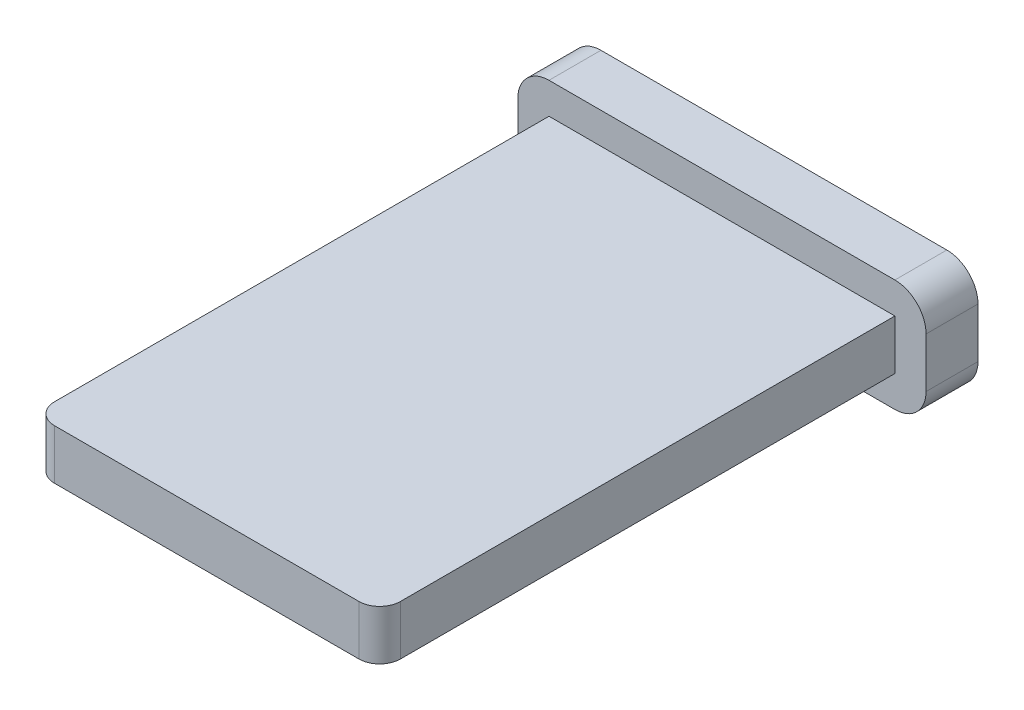
from build123d import *

# Parameters (mm, degrees)
SKETCH1_W           = 33.3
SKETCH1_H           = 4.8
BOSS_EXTRUDE1_DEPTH = 49.6
FILLET1_R           = 2
SKETCH2_W           = 39.3
SKETCH2_H           = 10.8
BOSS_EXTRUDE2_DEPTH = 5
FILLET2_R           = 3
SKETCH3_W           = 0.284935898
SKETCH3_H           = 3.175
SKETCH3_W_2         = 0.284935897
SKETCH3_H_2         = 3.256410257
CUT_EXTRUDE1_DEPTH  = 2


with BuildPart() as part:
    # Sketch1 → Boss-Extrude1 (new body)
    with BuildSketch(Plane.XY):
        with Locations((0.05, 3.701923077)):
            Rectangle(SKETCH1_W, SKETCH1_H)
    extrude(amount=BOSS_EXTRUDE1_DEPTH)

    # Fillet1
    fillet1_edges = [part.edges().sort_by_distance(p)[0] for p in [
        (16.7, 3.701923077, 49.6),
        (-16.6, 3.701923077, 49.6),
    ]]
    fillet(fillet1_edges, radius=FILLET1_R)

    # Sketch2 → Boss-Extrude2 (add)
    with BuildSketch(Plane(origin=(0, 0, 0), x_dir=(-1, 0, 0), z_dir=(0, 0, -1))):
        with Locations((-0.05, 3.701923077)):
            Rectangle(SKETCH2_W, SKETCH2_H)
    extrude(amount=BOSS_EXTRUDE2_DEPTH)

    # Fillet2
    fillet2_edges = [part.edges().sort_by_distance(p)[0] for p in [
        (19.7, 9.101923077, -2.5),
        (19.7, -1.698076923, -2.5),
        (-19.6, -1.698076923, -2.5),
        (-19.6, 9.101923077, -2.5),
    ]]
    fillet(fillet2_edges, radius=FILLET2_R)

    # Sketch3 → Cut-Extrude1 (cut)
    with BuildSketch(Plane(origin=(0, 0, -5), x_dir=(-1, 0, 0), z_dir=(0, 0, -1))):
        with Locations((-13.121509951, 5.188376866)):
            Rectangle(SKETCH3_W, SKETCH3_H)
        Polygon((-11.961413797, 6.857287123), (-11.6764779, 6.857287123), (-11.6764779, 5.921069174), (-11.269426618, 5.921069174), (-11.269426618, 5.636133277), (-11.6764779, 5.636133277), (-11.6764779, 3.600876866), (-11.961413797, 3.600876866), (-11.961413797, 5.636133277), (-12.368465079, 5.636133277), (-12.368465079, 5.921069174), (-11.961413797, 5.921069174), align=None)
        with BuildLine():
            Line((-8.420067644, 5.921069174), (-8.420067644, 3.600876866))
            Line((-8.420067644, 3.600876866), (-8.705003541, 3.600876866))
            Line((-8.705003541, 3.600876866), (-8.705003541, 4.00220399))
            add(Edge.make_bspline(
                [(-8.705003541, 4.00220399), (-8.737133444, 3.965882358), (-8.799835353, 3.895000237), (-8.904556939, 3.802397124), (-9.015562358, 3.725853932), (-9.132312842, 3.664032223), (-9.254702962, 3.617593714), (-9.382461413, 3.58458627), (-9.515640309, 3.56336472), (-9.606583516, 3.561245614), (-9.652669807, 3.560171738)],
                knots=[0, 0, 0, 0, 1.074387032, 2.096679803, 3.090159297, 4.057316773, 5.018401886, 5.985159533, 6.978961417, 8, 8, 8, 8], degree=3))
            add(Edge.make_bspline(
                [(-9.652669807, 3.560171738), (-9.693643594, 3.561284233), (-9.774445715, 3.563478122), (-9.893307807, 3.580498212), (-10.00769149, 3.60783099), (-10.117704852, 3.645841083), (-10.222636013, 3.696260828), (-10.323383386, 3.756623246), (-10.419425043, 3.828505999), (-10.509297082, 3.910682282), (-10.592057539, 3.999940592), (-10.664684551, 4.095141195), (-10.72523913, 4.195872428), (-10.775875918, 4.300858931), (-10.814879744, 4.410908894), (-10.842070113, 4.525641754), (-10.859070375, 4.644921853), (-10.861263357, 4.726146992), (-10.862375336, 4.767333197)],
                knots=[0, 0, 0, 0, 1.033919861, 2.038935746, 3.024066025, 3.998881131, 4.97069526, 5.957263378, 6.95902576, 7.993208707, 9.027059324, 10.027763471, 11.009749337, 11.988697705, 12.965288445, 13.950418724, 14.960734635, 16, 16, 16, 16], degree=3))
            add(Edge.make_bspline(
                [(-10.862375336, 4.767333197), (-10.861238712, 4.807668128), (-10.858991667, 4.88740811), (-10.842251961, 5.004682358), (-10.814102403, 5.117638209), (-10.774598284, 5.225912007), (-10.723941653, 5.329634767), (-10.662321174, 5.428879847), (-10.589732397, 5.523920657), (-10.506046285, 5.612522413), (-10.415391172, 5.694365399), (-10.31840968, 5.765493604), (-10.217514275, 5.82692246), (-10.111139973, 5.875593828), (-10.000861242, 5.914972087), (-9.885696331, 5.94221628), (-9.766124398, 5.958270278), (-9.684943738, 5.960595071), (-9.64376556, 5.961774302)],
                knots=[0, 0, 0, 0, 1.020392517, 2.01726096, 2.990465484, 3.961182959, 4.928053699, 5.906110375, 6.912531644, 7.948652711, 8.985773172, 9.998621852, 10.987621588, 11.969261332, 12.953316658, 13.946091881, 14.958173133, 16, 16, 16, 16], degree=3))
            add(Edge.make_bspline(
                [(-9.64376556, 5.961774302), (-9.596412831, 5.960470056), (-9.503556364, 5.957912491), (-9.367731669, 5.936628446), (-9.239239893, 5.900670693), (-9.117089159, 5.85175982), (-9.001718109, 5.786764187), (-8.894218973, 5.704776651), (-8.793466713, 5.606314289), (-8.735064591, 5.530685386), (-8.705003541, 5.491757275)],
                knots=[0, 0, 0, 0, 1.038897134, 2.037228247, 3.008116434, 3.962042015, 4.918381754, 5.904844433, 6.921570401, 8, 8, 8, 8], degree=3))
            Line((-8.705003541, 5.491757275), (-8.705003541, 5.921069174))
            Line((-8.705003541, 5.921069174), (-8.420067644, 5.921069174))
        make_face()
        with BuildLine():
            add(Edge.make_bspline(
                [(-9.639949454, 5.676838405), (-9.681600318, 5.675356462), (-9.763812498, 5.672431343), (-9.884502414, 5.649595386), (-9.999993868, 5.611600076), (-10.109709236, 5.559637208), (-10.211915404, 5.494296854), (-10.303258948, 5.415265314), (-10.38448697, 5.324698879), (-10.452802324, 5.223006251), (-10.508492275, 5.113987554), (-10.547650939, 5.000028242), (-10.573476614, 4.883183727), (-10.576115057, 4.80393329), (-10.577439438, 4.764153108)],
                knots=[0, 0, 0, 0, 1.031046209, 2.035121221, 3.029706178, 4.034933723, 5.034054252, 6.02443088, 7.017295772, 8.038157696, 9.050218397, 10.03989886, 11.016116709, 12, 12, 12, 12], degree=3))
            add(Edge.make_bspline(
                [(-10.577439438, 4.764153108), (-10.575747714, 4.724610654), (-10.572370895, 4.645680738), (-10.548104194, 4.528676929), (-10.507391737, 4.414690763), (-10.451836438, 4.304689719), (-10.382270714, 4.202559856), (-10.301636008, 4.110267031), (-10.209152538, 4.030901476), (-10.106711157, 3.964464534), (-9.997302498, 3.910795676), (-9.882246003, 3.87345256), (-9.763704531, 3.849342716), (-9.683102771, 3.846526512), (-9.642493525, 3.845107636)],
                knots=[0, 0, 0, 0, 0.979072187, 1.954306742, 2.945804271, 3.96968567, 4.997920485, 5.998718438, 6.996577872, 8.005894225, 9.015743152, 10.005417472, 10.995077863, 12, 12, 12, 12], degree=3))
            add(Edge.make_bspline(
                [(-9.642493525, 3.845107636), (-9.601267055, 3.84661346), (-9.519271694, 3.849608395), (-9.398223723, 3.872542115), (-9.280753293, 3.910432382), (-9.168460593, 3.962955161), (-9.063852388, 4.028049334), (-8.969965028, 4.104255766), (-8.890575542, 4.192886512), (-8.823272246, 4.290292294), (-8.770498832, 4.397073891), (-8.732057693, 4.510769907), (-8.709330221, 4.6313843), (-8.706465709, 4.713810862), (-8.705003541, 4.755884879)],
                knots=[0, 0, 0, 0, 1.01762866, 2.023962475, 3.030623092, 4.058876274, 5.077231937, 6.066672613, 7.034107872, 8.005628644, 8.981990164, 9.965428785, 10.961468474, 12, 12, 12, 12], degree=3))
            add(Edge.make_bspline(
                [(-8.705003541, 4.755884879), (-8.705874086, 4.78794134), (-8.707587595, 4.851038599), (-8.720678183, 4.943682847), (-8.741501581, 5.032341298), (-8.770844178, 5.117107166), (-8.809389843, 5.197511787), (-8.855878888, 5.274132484), (-8.911128832, 5.346570754), (-8.974250277, 5.413829111), (-9.043342997, 5.475175974), (-9.116453759, 5.529934963), (-9.194448765, 5.574919064), (-9.276016363, 5.612149361), (-9.361298073, 5.641775875), (-9.45098785, 5.661540426), (-9.544132359, 5.675111574), (-9.607674138, 5.676256734), (-9.639949454, 5.676838405)],
                knots=[0, 0, 0, 0, 1.050140795, 2.067009409, 3.05949893, 4.030605086, 5.00011959, 5.97591094, 6.962425594, 7.979863591, 8.993523472, 9.986985069, 10.967611495, 11.937549037, 12.921786183, 13.919465291, 14.943216303, 16, 16, 16, 16], degree=3))
        make_face(mode=Mode.SUBTRACT)
        with Locations((-7.667022772, 5.229081995)):
            Rectangle(SKETCH3_W_2, SKETCH3_H_2)
        with BuildLine():
            add(Edge.make_bspline(
                [(-5.752609711, 5.961774302), (-5.70907477, 5.960847301), (-5.623713392, 5.959029678), (-5.498701952, 5.939603245), (-5.379371722, 5.909896707), (-5.265265676, 5.868828933), (-5.15784518, 5.813781735), (-5.055545551, 5.748096164), (-4.958647264, 5.670279097), (-4.900569231, 5.610082849), (-4.871089278, 5.579527708)],
                knots=[0, 0, 0, 0, 1.054011418, 2.066658804, 3.057071809, 4.030435133, 4.997543892, 5.974964718, 6.972108034, 8, 8, 8, 8], degree=3))
            add(Edge.make_bspline(
                [(-4.871089278, 5.579527708), (-4.845705648, 5.550305021), (-4.795429632, 5.492425186), (-4.730962873, 5.398576166), (-4.675426172, 5.301384789), (-4.630919057, 5.199560428), (-4.595826214, 5.093991976), (-4.570910904, 4.98431658), (-4.55609097, 4.870776451), (-4.554092565, 4.793665827), (-4.553080464, 4.754612844)],
                knots=[0, 0, 0, 0, 1.025258237, 2.030674902, 3.01204498, 3.988269485, 4.97094183, 5.956517959, 6.965070386, 8, 8, 8, 8], degree=3))
            add(Edge.make_bspline(
                [(-4.553080464, 4.754612844), (-4.553970677, 4.715333506), (-4.55572978, 4.637715702), (-4.57237006, 4.523398135), (-4.598251831, 4.412549974), (-4.635292142, 4.305635302), (-4.682788426, 4.202327308), (-4.740746407, 4.103077217), (-4.809572803, 4.007689211), (-4.887590714, 3.916973257), (-4.973816345, 3.833365334), (-5.067357422, 3.760496118), (-5.166375724, 3.698065164), (-5.272187909, 3.647776415), (-5.3838277, 3.608125473), (-5.501535898, 3.580276172), (-5.62512964, 3.563438073), (-5.70951862, 3.561275832), (-5.752609711, 3.560171738)],
                knots=[0, 0, 0, 0, 0.998656419, 1.973391657, 2.932242238, 3.890759089, 4.846373663, 5.82037756, 6.809684879, 7.83454468, 8.860553229, 9.859544525, 10.845671541, 11.83227036, 12.833544569, 13.85385346, 14.904124723, 16, 16, 16, 16], degree=3))
            add(Edge.make_bspline(
                [(-5.752609711, 3.560171738), (-5.795911921, 3.561279538), (-5.880721486, 3.563449219), (-6.004751484, 3.580210754), (-6.122670638, 3.608112638), (-6.234456581, 3.647906721), (-6.340723693, 3.698066771), (-6.440315729, 3.760307375), (-6.533932795, 3.833386945), (-6.620176667, 3.916967402), (-6.698189687, 4.007690719), (-6.767017345, 4.103076826), (-6.824974998, 4.20232741), (-6.872471369, 4.305635275), (-6.909511656, 4.412549981), (-6.935393433, 4.523398133), (-6.952033712, 4.637715703), (-6.953792815, 4.715333506), (-6.954683028, 4.754612844)],
                knots=[0, 0, 0, 0, 1.099876186, 2.154163076, 3.173186993, 4.173200201, 5.163417411, 6.152872554, 7.150605724, 8.17532212, 9.198891216, 10.186952605, 11.159729845, 12.11414092, 13.071450619, 14.029093627, 15.002601286, 16, 16, 16, 16], degree=3))
            add(Edge.make_bspline(
                [(-6.954683028, 4.754612844), (-6.953664025, 4.793453568), (-6.951646574, 4.870351526), (-6.936841541, 4.983678216), (-6.912023422, 5.093167991), (-6.876888512, 5.198328958), (-6.831971161, 5.299707104), (-6.77721485, 5.397138629), (-6.71209049, 5.490563277), (-6.662014434, 5.548368306), (-6.636674214, 5.577619655)],
                knots=[0, 0, 0, 0, 1.031353054, 2.041901799, 3.029428768, 4.008703097, 4.981709435, 5.96992636, 6.972712378, 8, 8, 8, 8], degree=3))
            add(Edge.make_bspline(
                [(-6.636674214, 5.577619655), (-6.607238706, 5.608439778), (-6.549348601, 5.669052974), (-6.45196797, 5.746643192), (-6.349920004, 5.813695631), (-6.241312392, 5.867649055), (-6.127300085, 5.910138282), (-6.007358344, 5.939679856), (-5.881922697, 5.958959685), (-5.796143613, 5.960826747), (-5.752609711, 5.961774302)],
                knots=[0, 0, 0, 0, 1.027980169, 2.021703884, 2.998553061, 3.971491411, 4.943284454, 5.930300938, 6.949603206, 8, 8, 8, 8], degree=3))
        make_face()
        with BuildLine():
            add(Edge.make_bspline(
                [(-5.753881746, 5.676838405), (-5.784668008, 5.675963382), (-5.845445789, 5.674235926), (-5.934907841, 5.661096955), (-6.021032123, 5.640280291), (-6.103982032, 5.610703754), (-6.183477838, 5.572514039), (-6.259595653, 5.525607169), (-6.332559367, 5.470604416), (-6.400941667, 5.407591849), (-6.463699907, 5.338758761), (-6.518562072, 5.26541775), (-6.56521199, 5.188758422), (-6.604074134, 5.108701059), (-6.633018512, 5.024434369), (-6.654039753, 4.936912654), (-6.667166329, 4.845957597), (-6.668877543, 4.784125816), (-6.669747131, 4.752704791)],
                knots=[0, 0, 0, 0, 1.021534396, 2.016698045, 2.994645724, 3.958388632, 4.93408049, 5.916473867, 6.921342795, 7.962252576, 8.998418191, 10.008913653, 10.997312074, 11.973003931, 12.956656626, 13.948281152, 14.957379055, 16, 16, 16, 16], degree=3))
            add(Edge.make_bspline(
                [(-6.669747131, 4.752704791), (-6.668289512, 4.712108309), (-6.665396412, 4.631531884), (-6.641869447, 4.512867509), (-6.602511893, 4.398946829), (-6.549364861, 4.290437678), (-6.482774934, 4.190042112), (-6.404318809, 4.10053298), (-6.31483851, 4.023257279), (-6.215400685, 3.959139655), (-6.10803641, 3.908194734), (-5.994411033, 3.872091377), (-5.875901261, 3.848622056), (-5.794910883, 3.846289362), (-5.753881746, 3.845107636)],
                knots=[0, 0, 0, 0, 1.016792936, 2.018143844, 3.017858371, 4.030088057, 5.03801393, 6.028138512, 7.003788237, 7.991172063, 8.984598303, 9.972568034, 10.972917682, 12, 12, 12, 12], degree=3))
            add(Edge.make_bspline(
                [(-5.753881746, 3.845107636), (-5.712854969, 3.846296247), (-5.631869249, 3.848642533), (-5.513524139, 3.871973176), (-5.400209322, 3.908352926), (-5.292956563, 3.959082359), (-5.193564001, 4.023500764), (-5.103440155, 4.10009662), (-5.025653915, 4.190279185), (-4.959129859, 4.290570658), (-4.905112457, 4.398778606), (-4.865939124, 4.512888534), (-4.8423556, 4.63152653), (-4.839470134, 4.712106515), (-4.838016361, 4.752704791)],
                knots=[0, 0, 0, 0, 1.02726834, 2.027799167, 3.010890988, 4.004497153, 4.992059811, 5.971914811, 6.958719428, 7.966827853, 8.981595046, 9.981490638, 10.983022906, 12, 12, 12, 12], degree=3))
            add(Edge.make_bspline(
                [(-4.838016361, 4.752704791), (-4.838885649, 4.784126004), (-4.840596275, 4.845958155), (-4.853727136, 4.936910523), (-4.874732518, 5.024442186), (-4.903735342, 5.108672217), (-4.942428626, 5.188965703), (-4.989978146, 5.26519267), (-5.04461629, 5.339012823), (-5.108131821, 5.40736934), (-5.176442743, 5.47062898), (-5.249436027, 5.525628497), (-5.325440972, 5.572307888), (-5.404705829, 5.611030406), (-5.487666373, 5.640011207), (-5.573669983, 5.661217152), (-5.662750332, 5.674180402), (-5.723310321, 5.675946737), (-5.753881746, 5.676838405)],
                knots=[0, 0, 0, 0, 1.042956736, 2.052379634, 3.044323526, 4.02829302, 5.004299113, 5.996692471, 7.007513377, 8.048758398, 9.090003419, 10.095195979, 11.07790575, 12.047570684, 13.018257071, 13.989683339, 14.985167495, 16, 16, 16, 16], degree=3))
        make_face(mode=Mode.SUBTRACT)
        with BuildLine():
            Line((-2.680644567, 6.775876866), (-2.057983309, 6.775876866))
            add(Edge.make_bspline(
                [(-2.057983309, 6.775876866), (-2.015156272, 6.775829789), (-1.933097769, 6.775739587), (-1.815427683, 6.773004782), (-1.708557426, 6.769351997), (-1.612717438, 6.764288422), (-1.527612834, 6.758304372), (-1.453628713, 6.749911451), (-1.390183544, 6.741148183), (-1.352168407, 6.732238764), (-1.334831265, 6.728175544)],
                knots=[0, 0, 0, 0, 1.415646017, 2.712440637, 3.8905458, 4.950247383, 5.884950622, 6.709939814, 7.411656543, 8, 8, 8, 8], degree=3))
            add(Edge.make_bspline(
                [(-1.334831265, 6.728175544), (-1.312884274, 6.72216849), (-1.269507445, 6.71029593), (-1.207004356, 6.686516338), (-1.147537653, 6.658320373), (-1.090903311, 6.626185799), (-1.037797278, 6.588733895), (-0.987427227, 6.547482827), (-0.940237673, 6.50148019), (-0.896493982, 6.451241947), (-0.856321344, 6.397611471), (-0.821732275, 6.339788163), (-0.792769719, 6.278745338), (-0.76792918, 6.214525455), (-0.750050796, 6.146589233), (-0.736582537, 6.075408715), (-0.72803396, 6.000991532), (-0.727215208, 5.950137224), (-0.726798413, 5.924249262)],
                knots=[0, 0, 0, 0, 0.999701418, 1.975846123, 2.934577507, 3.890451536, 4.834027766, 5.787354733, 6.749476667, 7.726910423, 8.712836071, 9.690891519, 10.682875813, 11.679750201, 12.712814741, 13.765529915, 14.8625177, 16, 16, 16, 16], degree=3))
            add(Edge.make_bspline(
                [(-0.726798413, 5.924249262), (-0.727180705, 5.898143708), (-0.727928686, 5.847066427), (-0.736906031, 5.77234254), (-0.748998419, 5.700933715), (-0.767592173, 5.632998285), (-0.791945034, 5.568939693), (-0.820512825, 5.507779004), (-0.854969313, 5.45055673), (-0.894561409, 5.397065131), (-0.938604641, 5.347253996), (-0.986912663, 5.30148429), (-1.03929045, 5.260023925), (-1.095571541, 5.222779957), (-1.156304619, 5.190616046), (-1.220568572, 5.161807634), (-1.288921983, 5.137613171), (-1.336222692, 5.124885901), (-1.36027197, 5.118414927)],
                knots=[0, 0, 0, 0, 1.121902311, 2.195077645, 3.232258892, 4.234102512, 5.217864754, 6.176164875, 7.132989551, 8.084763148, 9.034132444, 9.988522005, 10.94243251, 11.903244335, 12.886203696, 13.894208494, 14.929344452, 16, 16, 16, 16], degree=3))
            add(Edge.make_bspline(
                [(-1.36027197, 5.118414927), (-1.380163195, 5.114184937), (-1.42375597, 5.104914668), (-1.495549725, 5.094565568), (-1.579138753, 5.085732173), (-1.674408965, 5.079108998), (-1.781274843, 5.073439021), (-1.899794197, 5.06893225), (-2.030199682, 5.066455883), (-2.121160025, 5.066328164), (-2.168650376, 5.066261482)],
                knots=[0, 0, 0, 0, 0.601384939, 1.31797006, 2.144135048, 3.087295005, 4.142315834, 5.309527816, 6.595305764, 8, 8, 8, 8], degree=3))
            Line((-2.168650376, 5.066261482), (-2.395708669, 5.066261482))
            Line((-2.395708669, 5.066261482), (-2.395708669, 3.600876866))
            Line((-2.395708669, 3.600876866), (-2.680644567, 3.600876866))
            Line((-2.680644567, 3.600876866), (-2.680644567, 6.775876866))
        make_face()
        with BuildLine():
            Line((-2.395708669, 6.450235841), (-2.395708669, 5.391902507))
            Line((-2.395708669, 5.391902507), (-1.839829262, 5.384906313))
            add(Edge.make_bspline(
                [(-1.839829262, 5.384906313), (-1.812687615, 5.384892286), (-1.760291225, 5.384865206), (-1.684602651, 5.388480373), (-1.614381369, 5.392653713), (-1.549843076, 5.398764158), (-1.490958678, 5.407401299), (-1.437629991, 5.416120518), (-1.390270527, 5.428734668), (-1.334844823, 5.445719167), (-1.273083501, 5.474686611), (-1.205893653, 5.516732583), (-1.148951764, 5.570327225), (-1.099677309, 5.630586758), (-1.06057412, 5.697623825), (-1.031948327, 5.769350646), (-1.015128848, 5.845031624), (-1.012873515, 5.896818722), (-1.01173431, 5.922977227)],
                knots=[0, 0, 0, 0, 1.160613943, 2.240541288, 3.23993089, 4.169200891, 5.011653406, 5.7853311, 6.478053781, 7.106038997, 8.262395093, 9.384106736, 10.481365981, 11.59014053, 12.70357646, 13.786202915, 14.881775077, 16, 16, 16, 16], degree=3))
            add(Edge.make_bspline(
                [(-1.01173431, 5.922977227), (-1.012879711, 5.948502878), (-1.015156626, 5.999244714), (-1.032080159, 6.073611162), (-1.060518465, 6.144582122), (-1.099939804, 6.210779135), (-1.147783544, 6.270821836), (-1.203390805, 6.322979944), (-1.266630692, 6.364909631), (-1.325457302, 6.39197268), (-1.377709806, 6.408496537), (-1.423095941, 6.420057928), (-1.474341053, 6.429288656), (-1.531461824, 6.436763062), (-1.594015524, 6.443161559), (-1.662539566, 6.447503124), (-1.736774371, 6.450044445), (-1.788309675, 6.450170498), (-1.815024575, 6.450235841)],
                knots=[0, 0, 0, 0, 1.120700087, 2.227813068, 3.331159281, 4.466773991, 5.599788987, 6.693661531, 7.80175334, 8.91857717, 9.525282508, 10.207424825, 10.974604443, 11.810962634, 12.737642355, 13.736264703, 14.826523623, 16, 16, 16, 16], degree=3))
            Line((-1.815024575, 6.450235841), (-2.395708669, 6.450235841))
        make_face(mode=Mode.SUBTRACT)
        with BuildLine():
            add(Edge.make_bspline(
                [(0.148361844, 4.089338405), (0.16604225, 4.088287782), (0.200702621, 4.086228159), (0.250812402, 4.072097891), (0.2961647, 4.047007535), (0.336561808, 4.013567729), (0.369859826, 3.973022377), (0.395844345, 3.928031803), (0.409851525, 3.877502501), (0.411896145, 3.842641296), (0.412945177, 3.824755072)],
                knots=[0, 0, 0, 0, 1.020151414, 1.999887582, 2.974338812, 3.990962822, 5.007586832, 5.987933904, 6.967670073, 8, 8, 8, 8], degree=3))
            add(Edge.make_bspline(
                [(0.412945177, 3.824755072), (0.411860596, 3.807298622), (0.409721819, 3.772874761), (0.395876453, 3.722726577), (0.369661793, 3.677707885), (0.336791478, 3.636612374), (0.296154714, 3.603101727), (0.250705182, 3.578224836), (0.200820254, 3.563082826), (0.166061875, 3.56115397), (0.148361844, 3.560171738)],
                knots=[0, 0, 0, 0, 1.009421747, 1.99056486, 2.972319754, 3.999869655, 5.017953583, 5.993804169, 6.978383603, 8, 8, 8, 8], degree=3))
            add(Edge.make_bspline(
                [(0.148361844, 3.560171738), (0.130649058, 3.56111843), (0.09606906, 3.56296662), (0.046370337, 3.578535737), (0.000644015, 3.602868448), (-0.039984838, 3.636674858), (-0.073130451, 3.677496417), (-0.09819062, 3.723036618), (-0.113240255, 3.772731208), (-0.115219525, 3.807270348), (-0.11622149, 3.824755072)],
                knots=[0, 0, 0, 0, 1.022052826, 1.995314843, 2.982371812, 4.00089066, 5.028879526, 6.005146991, 6.990147033, 8, 8, 8, 8], degree=3))
            add(Edge.make_bspline(
                [(-0.11622149, 3.824755072), (-0.115258014, 3.84267058), (-0.113376946, 3.877648412), (-0.098159025, 3.927721888), (-0.07332489, 3.97323183), (-0.039755711, 4.01350587), (0.000634186, 4.047240066), (0.04626003, 4.0717917), (0.096188756, 4.086342645), (0.1306692, 4.0883225), (0.148361844, 4.089338405)],
                knots=[0, 0, 0, 0, 1.032775665, 2.016367738, 2.991239715, 4.008302682, 5.025365648, 6.011011707, 6.979408107, 8, 8, 8, 8], degree=3))
        make_face()
        with Locations((2.468554152, 5.188376866)):
            Rectangle(SKETCH3_W_2, SKETCH3_H)
        with BuildLine():
            Line((3.099483639, 4.213361842), (3.367883078, 4.374274302))
            add(Edge.make_bspline(
                [(3.367883078, 4.374274302), (3.39284605, 4.332487324), (3.440674142, 4.252425088), (3.520458589, 4.144241008), (3.603129158, 4.052291052), (3.689298054, 3.977110129), (3.778439307, 3.917920068), (3.871134841, 3.876008043), (3.967072284, 3.849867837), (4.032362822, 3.846692758), (4.064958398, 3.845107636)],
                knots=[0, 0, 0, 0, 1.272034388, 2.437168799, 3.508375237, 4.49857839, 5.41946034, 6.295179144, 7.148887113, 8, 8, 8, 8], degree=3))
            add(Edge.make_bspline(
                [(4.064958398, 3.845107636), (4.092795764, 3.845882946), (4.147983409, 3.84742), (4.229229158, 3.862189013), (4.308134078, 3.884878587), (4.383071914, 3.917373289), (4.45300865, 3.956687487), (4.514337581, 4.004172948), (4.567356555, 4.057337149), (4.610726252, 4.116648557), (4.644000284, 4.180436256), (4.669574517, 4.245910155), (4.683766834, 4.314098785), (4.685904746, 4.360009705), (4.686983639, 4.383178549)],
                knots=[0, 0, 0, 0, 1.095163259, 2.171163733, 3.241058638, 4.321873601, 5.38011039, 6.391990106, 7.366004449, 8.327778327, 9.272591725, 10.192022065, 11.087607919, 12, 12, 12, 12], degree=3))
            add(Edge.make_bspline(
                [(4.686983639, 4.383178549), (4.685646228, 4.409613463), (4.682927468, 4.463351779), (4.659948197, 4.54263575), (4.623799237, 4.621096867), (4.590450268, 4.669630158), (4.573136483, 4.694827187)],
                knots=[0, 0, 0, 0, 0.938893495, 1.908633276, 2.914225137, 4, 4, 4, 4], degree=3))
            add(Edge.make_bspline(
                [(4.573136483, 4.694827187), (4.558920997, 4.71301252), (4.529077363, 4.751190351), (4.47777162, 4.808018529), (4.417568073, 4.866636666), (4.350526991, 4.929283097), (4.274206261, 4.993044169), (4.190996301, 5.060960393), (4.098772658, 5.130448966), (4.034093829, 5.177051222), (4.000720618, 5.201097219)],
                knots=[0, 0, 0, 0, 0.722233717, 1.516239348, 2.393582979, 3.351407094, 4.387010283, 5.505090956, 6.712668013, 8, 8, 8, 8], degree=3))
            add(Edge.make_bspline(
                [(4.000720618, 5.201097219), (3.967315993, 5.224890295), (3.903448893, 5.270380844), (3.814132893, 5.337894302), (3.734263988, 5.399619812), (3.664197166, 5.456138452), (3.603963246, 5.507457886), (3.55308758, 5.553085302), (3.512866175, 5.594254675), (3.490500041, 5.620962178), (3.480458198, 5.632953188)],
                knots=[0, 0, 0, 0, 1.452282411, 2.77665338, 3.964542531, 5.026858415, 5.96415736, 6.766646006, 7.446254459, 8, 8, 8, 8], degree=3))
            add(Edge.make_bspline(
                [(3.480458198, 5.632953188), (3.466422389, 5.651641272), (3.438819087, 5.688393896), (3.402382782, 5.745838588), (3.371413684, 5.804642551), (3.347136426, 5.864963799), (3.326692856, 5.925955485), (3.312942447, 5.9884134), (3.304332395, 6.05205729), (3.303450664, 6.09488668), (3.30300928, 6.116326586)],
                knots=[0, 0, 0, 0, 1.068054152, 2.10047183, 3.106115577, 4.101338837, 5.06977816, 6.043150881, 7.020423561, 8, 8, 8, 8], degree=3))
            add(Edge.make_bspline(
                [(3.30300928, 6.116326586), (3.304193291, 6.149917881), (3.306536005, 6.216382482), (3.326348474, 6.313474735), (3.357620314, 6.406172414), (3.401430676, 6.493557788), (3.457906989, 6.573355499), (3.52326298, 6.646483448), (3.601106257, 6.707959234), (3.686516137, 6.761673029), (3.780002989, 6.803715404), (3.877966165, 6.835430008), (3.980561366, 6.853399834), (4.050051353, 6.855978628), (4.085310962, 6.857287123)],
                knots=[0, 0, 0, 0, 1.005424448, 1.989358655, 2.955360095, 3.929531133, 4.905563448, 5.876582895, 6.856512386, 7.866279853, 8.892233794, 9.918561126, 10.94386622, 12, 12, 12, 12], degree=3))
            add(Edge.make_bspline(
                [(4.085310962, 6.857287123), (4.122725253, 6.855996665), (4.197130337, 6.853430357), (4.306576411, 6.831116882), (4.411950775, 6.794195559), (4.496717165, 6.752295847), (4.563059027, 6.710448063), (4.613652863, 6.67233008), (4.664922265, 6.628446945), (4.717280786, 6.578681772), (4.769841242, 6.522577934), (4.823383945, 6.460519666), (4.878034103, 6.392886219), (4.913191205, 6.344603993), (4.931214408, 6.319852227)],
                knots=[0, 0, 0, 0, 1.286793592, 2.559021753, 3.825965368, 5.121522368, 5.803751409, 6.523245864, 7.299691795, 8.125521123, 9.008227632, 9.944561021, 10.946284179, 12, 12, 12, 12], degree=3))
            Line((4.931214408, 6.319852227), (4.673627268, 6.124594815))
            add(Edge.make_bspline(
                [(4.673627268, 6.124594815), (4.658073458, 6.144632413), (4.628120456, 6.183220141), (4.58264585, 6.237259835), (4.539784577, 6.286623355), (4.497556714, 6.329499579), (4.458192492, 6.368236514), (4.419986317, 6.401401436), (4.383488013, 6.429319298), (4.33748053, 6.459113098), (4.279679457, 6.488646498), (4.207122056, 6.513637448), (4.131297364, 6.528655254), (4.079654055, 6.530640887), (4.053510081, 6.531646097)],
                knots=[0, 0, 0, 0, 1.181633172, 2.275549214, 3.290209073, 4.226197932, 5.078386478, 5.862611352, 6.581680152, 7.217281963, 8.414376989, 9.595101626, 10.782541182, 12, 12, 12, 12], degree=3))
            add(Edge.make_bspline(
                [(4.053510081, 6.531646097), (4.02071095, 6.530546912), (3.957460915, 6.528427238), (3.86766263, 6.505276965), (3.786841712, 6.468826278), (3.717397599, 6.417740547), (3.659579056, 6.357215076), (3.617754818, 6.287565686), (3.592581455, 6.210655935), (3.589509615, 6.157006004), (3.587945177, 6.129682956)],
                knots=[0, 0, 0, 0, 1.14458467, 2.207223713, 3.21896685, 4.227309161, 5.202851033, 6.127160689, 7.046193047, 8, 8, 8, 8], degree=3))
            add(Edge.make_bspline(
                [(3.587945177, 6.129682956), (3.588301799, 6.112672686), (3.589015626, 6.078624332), (3.598971336, 6.02832197), (3.611761441, 5.978146684), (3.6320294, 5.928324055), (3.660010497, 5.877982744), (3.696754478, 5.826255882), (3.743030839, 5.772687546), (3.778479272, 5.737846571), (3.797194977, 5.719451586)],
                knots=[0, 0, 0, 0, 0.858281714, 1.717966888, 2.583508476, 3.4729293, 4.427298488, 5.488583878, 6.674047936, 8, 8, 8, 8], degree=3))
            add(Edge.make_bspline(
                [(3.797194977, 5.719451586), (3.804144936, 5.713249427), (3.820656448, 5.698514516), (3.850842467, 5.674391519), (3.890704862, 5.644634718), (3.939202716, 5.607816224), (3.997230251, 5.565106612), (4.064793849, 5.517051978), (4.141140382, 5.462092312), (4.195316692, 5.423667971), (4.223962805, 5.403350825)],
                knots=[0, 0, 0, 0, 0.420754252, 0.999615792, 1.744751191, 2.668019286, 3.750313428, 4.999500688, 6.413464383, 8, 8, 8, 8], degree=3))
            add(Edge.make_bspline(
                [(4.223962805, 5.403350825), (4.258421455, 5.378276163), (4.325145855, 5.329722555), (4.420085231, 5.256774046), (4.506167471, 5.185429284), (4.583694806, 5.116143883), (4.653433144, 5.049443399), (4.714608791, 4.984525371), (4.767845087, 4.921854887), (4.825157663, 4.841506908), (4.883720828, 4.742826924), (4.934014196, 4.621924522), (4.965726411, 4.500552146), (4.969873428, 4.418975658), (4.971919536, 4.378726426)],
                knots=[0, 0, 0, 0, 1.163667725, 2.253281268, 3.268753668, 4.215851969, 5.092017293, 5.902905408, 6.650798638, 7.335211899, 8.59617414, 9.77448103, 10.901945474, 12, 12, 12, 12], degree=3))
            add(Edge.make_bspline(
                [(4.971919536, 4.378726426), (4.971323418, 4.350261766), (4.970142758, 4.293885211), (4.956571072, 4.21110382), (4.936686804, 4.130702959), (4.906717313, 4.05367645), (4.870138448, 3.97861513), (4.823723352, 3.907487963), (4.769922809, 3.83872073), (4.708206465, 3.774147134), (4.640673397, 3.714868799), (4.569296045, 3.662137436), (4.493957583, 3.618169743), (4.41506671, 3.582291479), (4.332605305, 3.55423036), (4.246601101, 3.533898686), (4.15691233, 3.521420291), (4.095951893, 3.520125107), (4.064958398, 3.51946661)],
                knots=[0, 0, 0, 0, 0.983748083, 1.948392443, 2.894712957, 3.844097841, 4.80183111, 5.778335162, 6.776009319, 7.81870978, 8.863265674, 9.881300176, 10.883814829, 11.87499822, 12.874611388, 13.892143829, 14.928324115, 16, 16, 16, 16], degree=3))
            add(Edge.make_bspline(
                [(4.064958398, 3.51946661), (4.040977766, 3.519930325), (3.993318512, 3.520851914), (3.92282491, 3.528999219), (3.853755426, 3.540526377), (3.786976756, 3.55882714), (3.721628532, 3.581031255), (3.65799497, 3.608371028), (3.596045228, 3.64113449), (3.535432135, 3.678594976), (3.476309848, 3.722190216), (3.419232902, 3.772966173), (3.362328569, 3.829522453), (3.307276431, 3.893394893), (3.252962936, 3.963551582), (3.20045895, 4.040648913), (3.148677678, 4.124266941), (3.116187932, 4.18310884), (3.099483639, 4.213361842)],
                knots=[0, 0, 0, 0, 0.915332311, 1.819136955, 2.706846663, 3.586547465, 4.459518054, 5.340707479, 6.227863349, 7.133153174, 8.059268498, 9.028702269, 10.047606654, 11.120612155, 12.245963614, 13.433783089, 14.680604001, 16, 16, 16, 16], degree=3))
        make_face()
        with BuildLine():
            Line((5.623201587, 6.775876866), (6.245862845, 6.775876866))
            add(Edge.make_bspline(
                [(6.245862845, 6.775876866), (6.288689882, 6.775829789), (6.370748385, 6.775739587), (6.488418471, 6.773004782), (6.595288728, 6.769351997), (6.691128716, 6.764288422), (6.77623332, 6.758304372), (6.850217441, 6.749911451), (6.91366261, 6.741148183), (6.951677746, 6.732238764), (6.969014889, 6.728175544)],
                knots=[0, 0, 0, 0, 1.415646017, 2.712440637, 3.8905458, 4.950247383, 5.884950622, 6.709939814, 7.411656543, 8, 8, 8, 8], degree=3))
            add(Edge.make_bspline(
                [(6.969014889, 6.728175544), (6.99096188, 6.72216849), (7.034338709, 6.71029593), (7.096841798, 6.686516338), (7.156308501, 6.658320373), (7.212942843, 6.626185799), (7.266048876, 6.588733895), (7.316418927, 6.547482827), (7.363608481, 6.50148019), (7.407352172, 6.451241947), (7.44752481, 6.397611471), (7.482113879, 6.339788163), (7.511076435, 6.278745338), (7.535916974, 6.214525455), (7.553795358, 6.146589233), (7.567263617, 6.075408715), (7.575812193, 6.000991532), (7.576630946, 5.950137224), (7.577047741, 5.924249262)],
                knots=[0, 0, 0, 0, 0.999701418, 1.975846123, 2.934577507, 3.890451536, 4.834027766, 5.787354733, 6.749476667, 7.726910423, 8.712836071, 9.690891519, 10.682875813, 11.679750201, 12.712814741, 13.765529915, 14.8625177, 16, 16, 16, 16], degree=3))
            add(Edge.make_bspline(
                [(7.577047741, 5.924249262), (7.576665449, 5.898143708), (7.575917468, 5.847066427), (7.566940123, 5.77234254), (7.554847735, 5.700933715), (7.53625398, 5.632998285), (7.51190112, 5.568939693), (7.483333329, 5.507779004), (7.448876841, 5.45055673), (7.409284745, 5.397065131), (7.365241513, 5.347253996), (7.316933491, 5.30148429), (7.264555704, 5.260023925), (7.208274613, 5.222779957), (7.147541535, 5.190616046), (7.083277582, 5.161807634), (7.014924171, 5.137613171), (6.967623462, 5.124885901), (6.943574183, 5.118414927)],
                knots=[0, 0, 0, 0, 1.121902311, 2.195077645, 3.232258892, 4.234102512, 5.217864754, 6.176164875, 7.132989551, 8.084763148, 9.034132444, 9.988522005, 10.94243251, 11.903244335, 12.886203696, 13.894208494, 14.929344452, 16, 16, 16, 16], degree=3))
            add(Edge.make_bspline(
                [(6.943574183, 5.118414927), (6.923682959, 5.114184937), (6.880090184, 5.104914668), (6.808296429, 5.094565568), (6.7247074, 5.085732173), (6.629437189, 5.079108998), (6.522571311, 5.073439021), (6.404051956, 5.06893225), (6.273646472, 5.066455883), (6.182686129, 5.066328164), (6.135195778, 5.066261482)],
                knots=[0, 0, 0, 0, 0.601384939, 1.31797006, 2.144135048, 3.087295005, 4.142315834, 5.309527816, 6.595305764, 8, 8, 8, 8], degree=3))
            Line((6.135195778, 5.066261482), (5.908137485, 5.066261482))
            Line((5.908137485, 5.066261482), (5.908137485, 3.600876866))
            Line((5.908137485, 3.600876866), (5.623201587, 3.600876866))
            Line((5.623201587, 3.600876866), (5.623201587, 6.775876866))
        make_face()
        with BuildLine():
            Line((5.908137485, 6.450235841), (5.908137485, 5.391902507))
            Line((5.908137485, 5.391902507), (6.464016892, 5.384906313))
            add(Edge.make_bspline(
                [(6.464016892, 5.384906313), (6.491158539, 5.384892286), (6.543554929, 5.384865206), (6.619243503, 5.388480373), (6.689464785, 5.392653713), (6.754003078, 5.398764158), (6.812887476, 5.407401299), (6.866216163, 5.416120518), (6.913575626, 5.428734668), (6.969001331, 5.445719167), (7.030762653, 5.474686611), (7.097952501, 5.516732583), (7.15489439, 5.570327225), (7.204168845, 5.630586758), (7.243272034, 5.697623825), (7.271897827, 5.769350646), (7.288717306, 5.845031624), (7.290972638, 5.896818722), (7.292111844, 5.922977227)],
                knots=[0, 0, 0, 0, 1.160613943, 2.240541288, 3.23993089, 4.169200891, 5.011653406, 5.7853311, 6.478053781, 7.106038997, 8.262395093, 9.384106736, 10.481365981, 11.59014053, 12.70357646, 13.786202915, 14.881775077, 16, 16, 16, 16], degree=3))
            add(Edge.make_bspline(
                [(7.292111844, 5.922977227), (7.290966443, 5.948502878), (7.288689528, 5.999244714), (7.271765995, 6.073611162), (7.243327689, 6.144582122), (7.20390635, 6.210779135), (7.15606261, 6.270821836), (7.100455349, 6.322979944), (7.037215462, 6.364909631), (6.978388852, 6.39197268), (6.926136348, 6.408496537), (6.880750213, 6.420057928), (6.829505101, 6.429288656), (6.77238433, 6.436763062), (6.70983063, 6.443161559), (6.641306587, 6.447503124), (6.567071782, 6.450044445), (6.515536479, 6.450170498), (6.488821579, 6.450235841)],
                knots=[0, 0, 0, 0, 1.120700087, 2.227813068, 3.331159281, 4.466773991, 5.599788987, 6.693661531, 7.80175334, 8.91857717, 9.525282508, 10.207424825, 10.974604443, 11.810962634, 12.737642355, 13.736264703, 14.826523623, 16, 16, 16, 16], degree=3))
            Line((6.488821579, 6.450235841), (5.908137485, 6.450235841))
        make_face(mode=Mode.SUBTRACT)
    extrude(amount=-CUT_EXTRUDE1_DEPTH, mode=Mode.SUBTRACT)


solid = part.part
